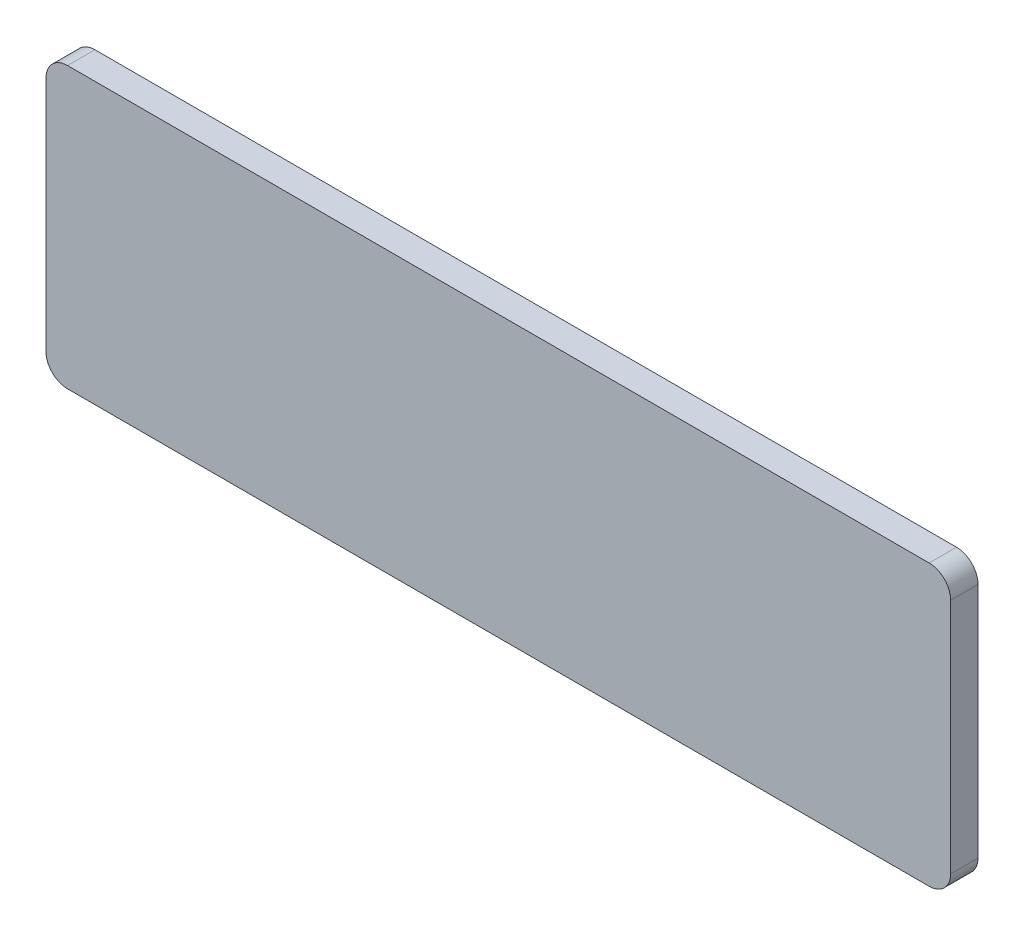
from build123d import *

# Parameters (mm, degrees)
SKETCH1_W           = 210
SKETCH1_H           = 65
BOSS_EXTRUDE1_DEPTH = 3.175
FILLET1_R           = 5


with BuildPart() as part:
    # Sketch1 → Boss-Extrude1 (new body, symmetric)
    with BuildSketch(Plane.XY):
        Rectangle(SKETCH1_W, SKETCH1_H)
    extrude(amount=BOSS_EXTRUDE1_DEPTH, both=True)

    # Fillet1
    fillet1_edges = [part.edges().sort_by_distance(p)[0] for p in [
        (-105, 32.5, 0),
        (105, 32.5, 0),
        (105, -32.5, 0),
        (-105, -32.5, 0),
    ]]
    fillet(fillet1_edges, radius=FILLET1_R)


solid = part.part
